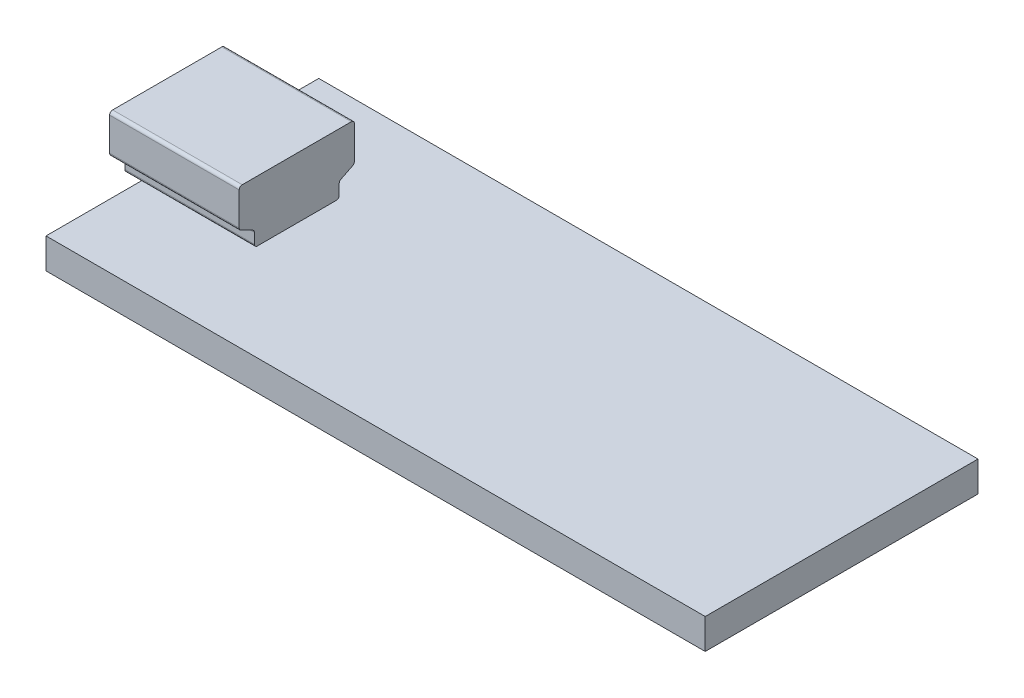
from build123d import *

# Parameters (mm, degrees)
SKETCH1_W           = 43.5
SKETCH1_H           = 18
BOSS_EXTRUDE1_DEPTH = 2
SKETCH2_W           = 7.549869754
SKETCH2_H           = 7.6
BOSS_EXTRUDE2_DEPTH = 4
BOSS_EXTRUDE3_DEPTH = 1
CUT_EXTRUDE1_DEPTH  = 15
CUT_EXTRUDE2_DEPTH  = 8


with BuildPart() as part:
    # Sketch1 → Boss-Extrude1 (new body)
    with BuildSketch(Plane(origin=(0, 0, 0), x_dir=(1, 0, 0), z_dir=(0, 1, 0))):
        Rectangle(SKETCH1_W, SKETCH1_H)
    extrude(amount=BOSS_EXTRUDE1_DEPTH)

    # Sketch2 → Boss-Extrude2 (add)
    with BuildSketch(Plane(origin=(0, 2, 0), x_dir=(1, 0, 0), z_dir=(0, 1, 0))):
        with Locations((-17.975065123, 0)):
            Rectangle(SKETCH2_W, SKETCH2_H)
    extrude(amount=BOSS_EXTRUDE2_DEPTH)

    # Sketch3 → Boss-Extrude3 (add)
    with BuildSketch(Plane.ZY.offset(21.75)):
        with BuildLine():
            ThreePointArc((-3.8, 3.623606798), (-3.770130162, 3.518460575), (-3.689442719, 3.44472136))
            Line((-3.689442719, 3.44472136), (-2.910557281, 3.05527864))
            ThreePointArc((-2.910557281, 3.05527864), (-2.829869838, 2.981539425), (-2.8, 2.876393202))
            Line((-2.8, 2.876393202), (-2.8, 2.2))
            ThreePointArc((-2.8, 2.2), (-2.741421356, 2.058578644), (-2.6, 2))
            Line((-2.6, 2), (2.6, 2))
            ThreePointArc((2.6, 2), (2.741421356, 2.058578644), (2.8, 2.2))
            Line((2.8, 2.2), (2.8, 2.876393202))
            ThreePointArc((2.8, 2.876393202), (2.829869838, 2.981539425), (2.910557281, 3.05527864))
            Line((2.910557281, 3.05527864), (3.689442719, 3.44472136))
            ThreePointArc((3.689442719, 3.44472136), (3.770130162, 3.518460575), (3.8, 3.623606798))
            Line((3.8, 3.623606798), (3.8, 5.8))
            ThreePointArc((3.8, 5.8), (3.741421356, 5.941421356), (3.6, 6))
            Line((3.6, 6), (-3.6, 6))
            ThreePointArc((-3.6, 6), (-3.741421356, 5.941421356), (-3.8, 5.8))
            Line((-3.8, 5.8), (-3.8, 3.623606798))
        make_face()
    extrude(amount=BOSS_EXTRUDE3_DEPTH)

    # Sketch6 → Cut-Extrude1 (cut)
    with BuildSketch(Plane.ZY.offset(22.75)):
        with BuildLine():
            Line((-2.910557281, 3.05527864), (-3.689442719, 3.44472136))
            ThreePointArc((-3.689442719, 3.44472136), (-3.770130162, 3.518460575), (-3.8, 3.623606798))
            Line((-3.8, 3.623606798), (-3.8, 2))
            Line((-3.8, 2), (-2.6, 2))
            ThreePointArc((-2.6, 2), (-2.741421356, 2.058578644), (-2.8, 2.2))
            Line((-2.8, 2.2), (-2.8, 2.876393202))
            ThreePointArc((-2.8, 2.876393202), (-3.170130162, 2.77124698), (-2.910557281, 3.05527864))
        make_face()
        with BuildLine():
            Line((-3.8, 6), (-3.8, 5.8))
            ThreePointArc((-3.8, 5.8), (-3.741421356, 5.941421356), (-3.6, 6))
            Line((-3.6, 6), (-3.8, 6))
        make_face()
        with BuildLine():
            ThreePointArc((-2.8, 2.876393202), (-2.829869838, 2.981539425), (-2.910557281, 3.05527864))
            ThreePointArc((-2.910557281, 3.05527864), (-3.170130162, 2.77124698), (-2.8, 2.876393202))
        make_face()
        with BuildLine():
            ThreePointArc((2.910557281, 3.05527864), (2.829869838, 2.981539425), (2.8, 2.876393202))
            ThreePointArc((2.8, 2.876393202), (3, 2.676393202), (3.2, 2.876393202))
            ThreePointArc((3.2, 2.876393202), (3.105146222, 3.046523364), (2.910557281, 3.05527864))
        make_face()
        with BuildLine():
            ThreePointArc((2.8, 2.2), (2.741421356, 2.058578644), (2.6, 2))
            Line((2.6, 2), (3.8, 2))
            Line((3.8, 2), (3.8, 3.623606798))
            ThreePointArc((3.8, 3.623606798), (3.770130162, 3.518460575), (3.689442719, 3.44472136))
            Line((3.689442719, 3.44472136), (2.910557281, 3.05527864))
            ThreePointArc((2.910557281, 3.05527864), (3.105146222, 3.046523364), (3.2, 2.876393202))
            ThreePointArc((3.2, 2.876393202), (3, 2.676393202), (2.8, 2.876393202))
            Line((2.8, 2.876393202), (2.8, 2.2))
        make_face()
        with BuildLine():
            Line((3.8, 6), (3.6, 6))
            ThreePointArc((3.6, 6), (3.741421356, 5.941421356), (3.8, 5.8))
            Line((3.8, 5.8), (3.8, 6))
        make_face()
    extrude(amount=-CUT_EXTRUDE1_DEPTH, mode=Mode.SUBTRACT)

    # Sketch7 → Cut-Extrude2 (cut)
    with BuildSketch(Plane.ZY.offset(22.75)):
        with BuildLine():
            Line((3.1, 5.3), (-3.1, 5.3))
            Line((-3.1, 5.3), (-3.1, 3.932623792))
            Line((-3.1, 3.932623792), (-2.597507764, 3.681377674))
            ThreePointArc((-2.597507764, 3.681377674), (-2.234414272, 3.349551203), (-2.1, 2.876393202))
            Line((-2.1, 2.876393202), (-2.1, 2.7))
            Line((-2.1, 2.7), (2.1, 2.7))
            Line((2.1, 2.7), (2.1, 2.876393202))
            ThreePointArc((2.1, 2.876393202), (2.234414272, 3.349551203), (2.597507764, 3.681377674))
            Line((2.597507764, 3.681377674), (3.1, 3.932623792))
            Line((3.1, 3.932623792), (3.1, 5.3))
        make_face()
    extrude(amount=-CUT_EXTRUDE2_DEPTH, mode=Mode.SUBTRACT)


solid = part.part
